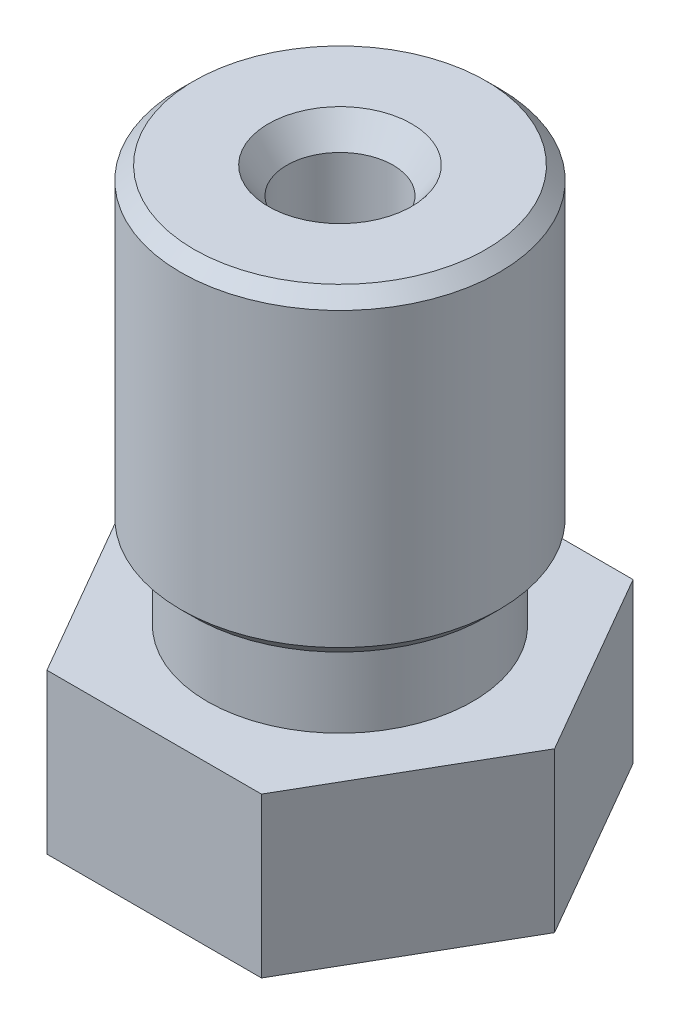
from build123d import *

# Parameters (mm, degrees)
SKETCH2_R           = 1.622490436
BOSS_EXTRUDE1_DEPTH = 3
CHAMFER1_SIZE       = 0.25


with BuildPart() as part:
    # Sketch1 → Revolve1 (revolve)
    with BuildSketch(Plane.XY):
        Polygon((0.2, -6.25), (0.2, -5.45), (0.75, -5.205124223), (0.75, -4.361307171), (1, -4.25), (1, 5.75), (1.350103769, 6.25), (3, 6.25), (3, 0.25), (2.5, 0.25), (2.5, -1.25), (3.5, -1.25), (3.5, -4.25), (1.900415076, -4.25), (0.5, -6.25), align=None)
    revolve(axis=Axis((0, -6.25, 0), (0, 1, 0)))

    # Sketch2 → Boss-Extrude1 (add)
    with BuildSketch(Plane.XZ.offset(4.25)):
        Polygon((2.020725942, 3.5), (-2.020725942, 3.5), (-4.041451884, 0), (-2.020725942, -3.5), (2.020725942, -3.5), (4.041451884, 0), align=None)
        Circle(SKETCH2_R, mode=Mode.SUBTRACT)
    extrude(amount=-BOSS_EXTRUDE1_DEPTH)

    # Chamfer1
    chamfer1_edges = [part.edges().sort_by_distance(p)[0] for p in [
        (-3, 0.25, 0),
        (-3, 6.25, 0),
    ]]
    chamfer(chamfer1_edges, length=CHAMFER1_SIZE)


solid = part.part
